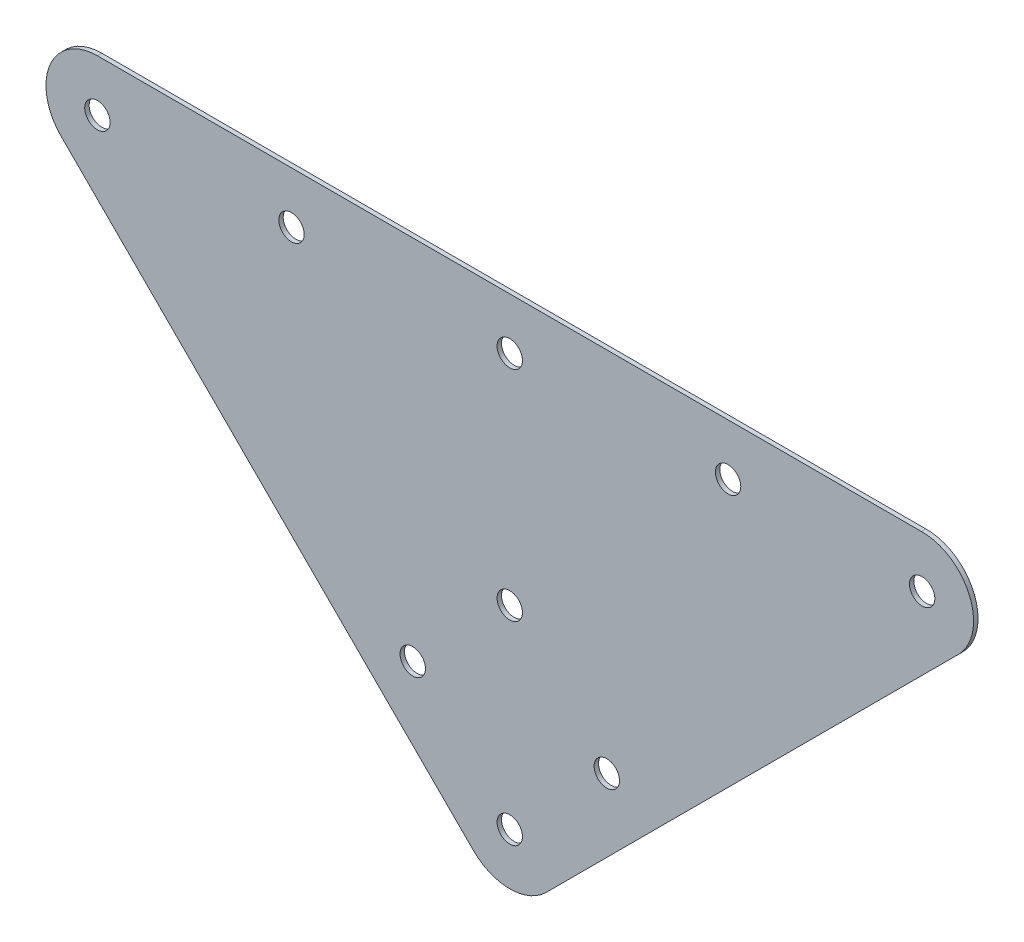
from build123d import *

# Parameters (mm, degrees)
SKETCH1_R           = 4.699
BOSS_EXTRUDE3_DEPTH = 1.641793186


with BuildPart() as part:
    # Sketch1 → Boss-Extrude3 (new body)
    with BuildSketch(Plane.XY):
        with BuildLine():
            Line((-46.269533378, 0), (-351.31947646, 0))
            ThreePointArc((-351.31947646, 0), (-368.919381572, -11.759880611), (-364.789860651, -32.520384191))
            Line((-364.789860651, -32.520384191), (-212.125506603, -185.184738239))
            ThreePointArc((-212.125506603, -185.184738239), (-198.655122421, -190.764354058), (-185.184738239, -185.184738239))
            Line((-185.184738239, -185.184738239), (-32.717500753, -32.717500753))
            ThreePointArc((-32.717500753, -32.717500753), (-28.388979015, -11.759100083), (-46.269533378, 0))
        make_face()
        with Locations((-198.655122421, -19.05)):
            Circle(SKETCH1_R, mode=Mode.SUBTRACT)
        with Locations((-279.477427511, -19.05)):
            Circle(SKETCH1_R, mode=Mode.SUBTRACT)
        with Locations((-117.832817213, -19.05)):
            Circle(SKETCH1_R, mode=Mode.SUBTRACT)
        with Locations((-351.319476479, -19.05)):
            Circle(SKETCH1_R, mode=Mode.SUBTRACT)
        with Locations((-45.990768365, -19.05)):
            Circle(SKETCH1_R, mode=Mode.SUBTRACT)
        with Locations((-198.655122421, -171.714354057)):
            Circle(SKETCH1_R, mode=Mode.SUBTRACT)
        with Locations((-162.734097937, -135.793329573)):
            Circle(SKETCH1_R, mode=Mode.SUBTRACT)
        with Locations((-234.576146906, -135.793329573)):
            Circle(SKETCH1_R, mode=Mode.SUBTRACT)
        with Locations((-198.655122421, -99.872305089)):
            Circle(SKETCH1_R, mode=Mode.SUBTRACT)
    extrude(amount=BOSS_EXTRUDE3_DEPTH)


solid = part.part
